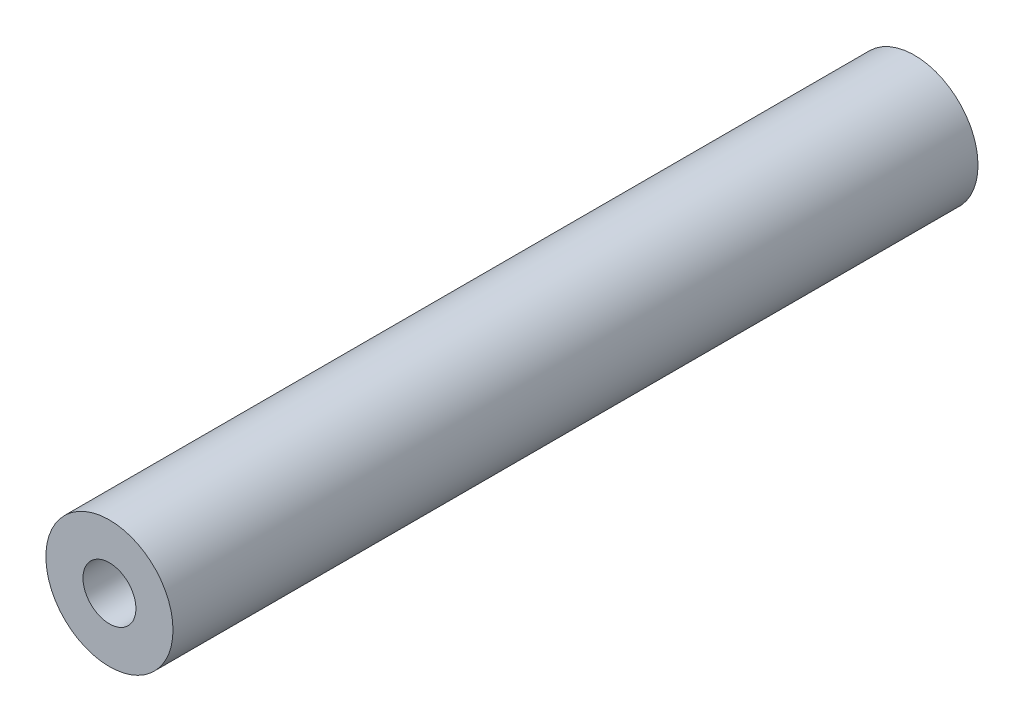
from build123d import *

# Parameters (mm, degrees)
SKETCH_1_R             = 6
EXTRUDE_1_DEPTH        = 76
HOLE_WIZARD_M6_1_D     = 5
HOLE_WIZARD_M6_1_DEPTH = 33
HOLE_WIZARD_M6_1_TIP   = 1.502151548
HOLE_WIZARD_M6_2_D     = 5
HOLE_WIZARD_M6_2_DEPTH = 33
HOLE_WIZARD_M6_2_TIP   = 1.502151548


with BuildPart() as part:
    # 草图1 → 凸台-拉伸1 (new body)
    with BuildSketch(Plane.XY):
        Circle(SKETCH_1_R)
    extrude(amount=EXTRUDE_1_DEPTH)

    # M6 螺纹孔1
    with Locations(Plane.XY.offset(76)):
        with Locations((0, 0)):
            Hole(HOLE_WIZARD_M6_1_D / 2, depth=HOLE_WIZARD_M6_1_DEPTH)
            with Locations((0, 0, -(HOLE_WIZARD_M6_1_DEPTH + HOLE_WIZARD_M6_1_TIP / 2))):  # 118° drill point
                Cone(0, HOLE_WIZARD_M6_1_D / 2, HOLE_WIZARD_M6_1_TIP, mode=Mode.SUBTRACT)

    # M6 螺纹孔2
    with Locations(Plane(origin=(0, 0, 0), x_dir=(-1, 0, 0), z_dir=(0, 0, -1))):
        with Locations((0, 0)):
            Hole(HOLE_WIZARD_M6_2_D / 2, depth=HOLE_WIZARD_M6_2_DEPTH)
            with Locations((0, 0, -(HOLE_WIZARD_M6_2_DEPTH + HOLE_WIZARD_M6_2_TIP / 2))):  # 118° drill point
                Cone(0, HOLE_WIZARD_M6_2_D / 2, HOLE_WIZARD_M6_2_TIP, mode=Mode.SUBTRACT)


solid = part.part
